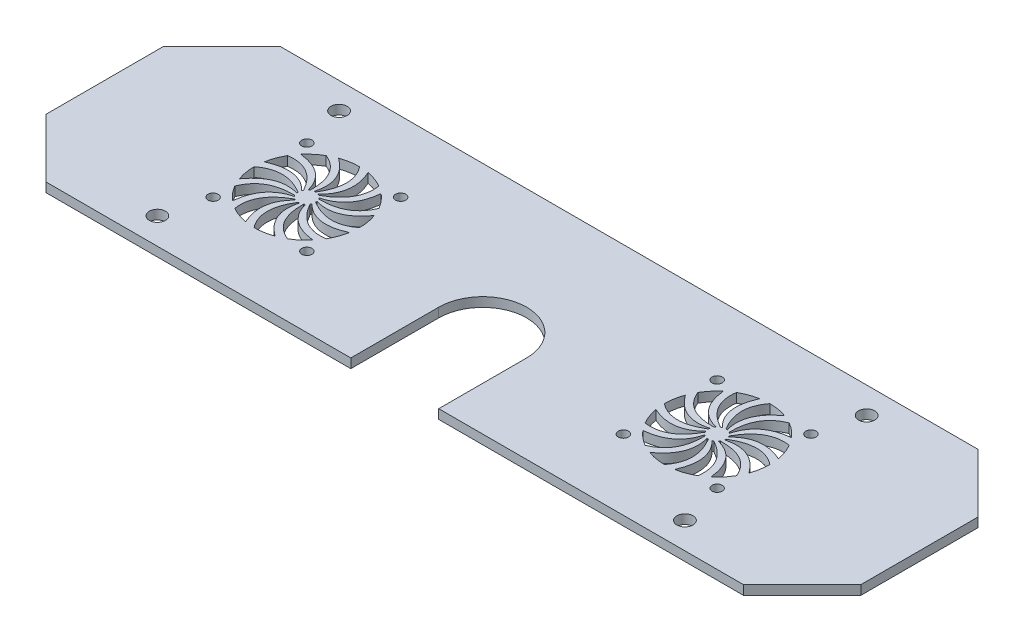
from build123d import *

# Parameters (mm, degrees)
SKETCH1_W             = 278
SKETCH1_H             = 80
BOSS_EXTRUDE1_DEPTH   = 3.175
CHAMFER1_SIZE         = 20
SKETCH2_R             = 1.75
CUT_EXTRUDE1_DEPTH    = 10
SKETCH3_R             = 2.75
CUT_EXTRUDE2_DEPTH    = 10
CUT_EXTRUDE3_DEPTH    = 10
CUT_EXTRUDE8_DEPTH    = 10
CIRPATTERN1_COUNT     = 12
MIRROR1_COPY_1_DEPTH  = 10
MIRROR1_COPY_2_DEPTH  = 10
MIRROR1_COPY_3_DEPTH  = 10
MIRROR1_COPY_4_DEPTH  = 10
MIRROR1_COPY_5_DEPTH  = 10
MIRROR1_COPY_6_DEPTH  = 10
MIRROR1_COPY_7_DEPTH  = 10
MIRROR1_COPY_8_DEPTH  = 10
MIRROR1_COPY_9_DEPTH  = 10
MIRROR1_COPY_10_DEPTH = 10
MIRROR1_COPY_11_DEPTH = 10


with BuildPart() as part:
    # Sketch1 → Boss-Extrude1 (new body)
    with BuildSketch(Plane(origin=(0, 0, 0), x_dir=(1, 0, 0), z_dir=(0, 1, 0))):
        Rectangle(SKETCH1_W, SKETCH1_H)
    extrude(amount=BOSS_EXTRUDE1_DEPTH)

    # Chamfer1
    chamfer1_edges = [part.edges().sort_by_distance(p)[0] for p in [
        (139, 1.5875, 40),
        (139, 1.5875, -40),
        (-139, 1.5875, -40),
        (-139, 1.5875, 40),
    ]]
    chamfer(chamfer1_edges, length=CHAMFER1_SIZE)

    # Sketch2 → Cut-Extrude1 (cut)
    with BuildSketch(Plane(origin=(0, 3.175, 0), x_dir=(1, 0, 0), z_dir=(0, 1, 0))):
        with Locations((-86, 16)):
            Circle(SKETCH2_R)
        with Locations((-54, 16)):
            Circle(SKETCH2_R)
        with Locations((-86, -16)):
            Circle(SKETCH2_R)
        with Locations((-54, -16)):
            Circle(SKETCH2_R)
        with Locations((54, -16)):
            Circle(SKETCH2_R)
        with Locations((86, -16)):
            Circle(SKETCH2_R)
        with Locations((54, 16)):
            Circle(SKETCH2_R)
        with Locations((86, 16)):
            Circle(SKETCH2_R)
    extrude(amount=-CUT_EXTRUDE1_DEPTH, mode=Mode.SUBTRACT)

    # Sketch3 → Cut-Extrude2 (cut)
    with BuildSketch(Plane(origin=(0, 3.175, 0), x_dir=(1, 0, 0), z_dir=(0, 1, 0))):
        with Locations((-90, 31)):
            Circle(SKETCH3_R)
        with Locations((-90, -31)):
            Circle(SKETCH3_R)
        with Locations((90, -31)):
            Circle(SKETCH3_R)
        with Locations((90, 31)):
            Circle(SKETCH3_R)
    extrude(amount=-CUT_EXTRUDE2_DEPTH, mode=Mode.SUBTRACT)

    # Sketch4 → Cut-Extrude3 (cut)
    with BuildSketch(Plane(origin=(0, 3.175, 0), x_dir=(1, 0, 0), z_dir=(0, 1, 0))):
        with BuildLine():
            Line((15, -40), (-15, -40))
            Line((-15, -40), (-15, -10))
            ThreePointArc((-15, -10), (0, 5), (15, -10))
            Line((15, -10), (15, -40))
        make_face()
    extrude(amount=-CUT_EXTRUDE3_DEPTH, mode=Mode.SUBTRACT)

    # Sketch6 → Cut-Extrude8 (cut)
    with BuildSketch(Plane(origin=(0, 3.175, 0), x_dir=(1, 0, 0), z_dir=(0, 1, 0))):
        with BuildLine():
            ThreePointArc((-67, 0), (-67.010104912, 0.246023091), (-67.040351574, 0.490388822))
            add(Edge.make_bspline(
                [(-67.040351574, 0.490388822), (-58.831315054, -1.84378005), (-53.060987789, 6.088502716)],
                knots=[0, 0, 0, 1, 1, 1], degree=2))
            ThreePointArc((-53.060987789, 6.088502716), (-52.26723062, 3.090127846), (-52, 0))
            add(Edge.make_bspline(
                [(-67, 0), (-58.536045734, -5.138256955), (-52, 0)],
                knots=[0, 0, 0, 1, 1, 1], degree=2))
        make_face()
    cut_extrude8 = extrude(amount=-CUT_EXTRUDE8_DEPTH, mode=Mode.SUBTRACT)

    # CirPattern1: Cut-Extrude8 ×12 about axis
    cirpattern1_axis = Axis((-70, 3.175, 0), (0, 1, 0))
    for i in range(1, CIRPATTERN1_COUNT):
        add(cut_extrude8.rotate(cirpattern1_axis, i * 360 / CIRPATTERN1_COUNT), mode=Mode.SUBTRACT)

    # Mirror1: Cut-Extrude8 across plane
    add(cut_extrude8.mirror(Plane(origin=(0, 0, 0), x_dir=(0, 0, 1), z_dir=(1, 0, 0))), mode=Mode.SUBTRACT)

    # Mirror1 copy 1 sketch → Mirror1 copy 1 (cut)
    with BuildSketch(Plane(origin=(9.378221735, 3.175, -35), x_dir=(-0.8660254037844387, 0, -0.49999999999999994), z_dir=(0, 1, 0))):
        with BuildLine():
            ThreePointArc((-67, 0), (-67.010104912, -0.246023091), (-67.040351574, -0.490388822))
            add(Edge.make_bspline(
                [(-67.040351574, -0.490388822), (-58.831315054, 1.84378005), (-53.060987789, -6.088502716)],
                knots=[0, 0, 0, 1, 1, 1], degree=2))
            ThreePointArc((-53.060987789, -6.088502716), (-52.26723062, -3.090127846), (-52, 0))
            add(Edge.make_bspline(
                [(-67, 0), (-58.536045734, 5.138256955), (-52, 0)],
                knots=[0, 0, 0, 1, 1, 1], degree=2))
        make_face()
    extrude(amount=-MIRROR1_COPY_1_DEPTH, mode=Mode.SUBTRACT)

    # Mirror1 copy 2 sketch → Mirror1 copy 2 (cut)
    with BuildSketch(Plane(origin=(35, 3.175, -60.621778265), x_dir=(-0.5000000000000001, 0, -0.8660254037844386), z_dir=(0, 1, 0))):
        with BuildLine():
            ThreePointArc((-67, 0), (-67.010104912, -0.246023091), (-67.040351574, -0.490388822))
            add(Edge.make_bspline(
                [(-67.040351574, -0.490388822), (-58.831315054, 1.84378005), (-53.060987789, -6.088502716)],
                knots=[0, 0, 0, 1, 1, 1], degree=2))
            ThreePointArc((-53.060987789, -6.088502716), (-52.26723062, -3.090127846), (-52, 0))
            add(Edge.make_bspline(
                [(-67, 0), (-58.536045734, 5.138256955), (-52, 0)],
                knots=[0, 0, 0, 1, 1, 1], degree=2))
        make_face()
    extrude(amount=-MIRROR1_COPY_2_DEPTH, mode=Mode.SUBTRACT)

    # Mirror1 copy 3 sketch → Mirror1 copy 3 (cut)
    with BuildSketch(Plane(origin=(70, 3.175, -70), x_dir=(0, 0, -1), z_dir=(0, 1, 0))):
        with BuildLine():
            ThreePointArc((-67, 0), (-67.010104912, -0.246023091), (-67.040351574, -0.490388822))
            add(Edge.make_bspline(
                [(-67.040351574, -0.490388822), (-58.831315054, 1.84378005), (-53.060987789, -6.088502716)],
                knots=[0, 0, 0, 1, 1, 1], degree=2))
            ThreePointArc((-53.060987789, -6.088502716), (-52.26723062, -3.090127846), (-52, 0))
            add(Edge.make_bspline(
                [(-67, 0), (-58.536045734, 5.138256955), (-52, 0)],
                knots=[0, 0, 0, 1, 1, 1], degree=2))
        make_face()
    extrude(amount=-MIRROR1_COPY_3_DEPTH, mode=Mode.SUBTRACT)

    # Mirror1 copy 4 sketch → Mirror1 copy 4 (cut)
    with BuildSketch(Plane(origin=(105, 3.175, -60.621778265), x_dir=(0.4999999999999998, 0, -0.8660254037844387), z_dir=(0, 1, 0))):
        with BuildLine():
            ThreePointArc((-67, 0), (-67.010104912, -0.246023091), (-67.040351574, -0.490388822))
            add(Edge.make_bspline(
                [(-67.040351574, -0.490388822), (-58.831315054, 1.84378005), (-53.060987789, -6.088502716)],
                knots=[0, 0, 0, 1, 1, 1], degree=2))
            ThreePointArc((-53.060987789, -6.088502716), (-52.26723062, -3.090127846), (-52, 0))
            add(Edge.make_bspline(
                [(-67, 0), (-58.536045734, 5.138256955), (-52, 0)],
                knots=[0, 0, 0, 1, 1, 1], degree=2))
        make_face()
    extrude(amount=-MIRROR1_COPY_4_DEPTH, mode=Mode.SUBTRACT)

    # Mirror1 copy 5 sketch → Mirror1 copy 5 (cut)
    with BuildSketch(Plane(origin=(130.621778265, 3.175, -35), x_dir=(0.8660254037844387, 0, -0.49999999999999994), z_dir=(0, 1, 0))):
        with BuildLine():
            ThreePointArc((-67, 0), (-67.010104912, -0.246023091), (-67.040351574, -0.490388822))
            add(Edge.make_bspline(
                [(-67.040351574, -0.490388822), (-58.831315054, 1.84378005), (-53.060987789, -6.088502716)],
                knots=[0, 0, 0, 1, 1, 1], degree=2))
            ThreePointArc((-53.060987789, -6.088502716), (-52.26723062, -3.090127846), (-52, 0))
            add(Edge.make_bspline(
                [(-67, 0), (-58.536045734, 5.138256955), (-52, 0)],
                knots=[0, 0, 0, 1, 1, 1], degree=2))
        make_face()
    extrude(amount=-MIRROR1_COPY_5_DEPTH, mode=Mode.SUBTRACT)

    # Mirror1 copy 6 sketch → Mirror1 copy 6 (cut)
    with BuildSketch(Plane(origin=(140, 3.175, 0), x_dir=(1, 0, 0), z_dir=(0, 1, 0))):
        with BuildLine():
            ThreePointArc((-67, 0), (-67.010104912, -0.246023091), (-67.040351574, -0.490388822))
            add(Edge.make_bspline(
                [(-67.040351574, -0.490388822), (-58.831315054, 1.84378005), (-53.060987789, -6.088502716)],
                knots=[0, 0, 0, 1, 1, 1], degree=2))
            ThreePointArc((-53.060987789, -6.088502716), (-52.26723062, -3.090127846), (-52, 0))
            add(Edge.make_bspline(
                [(-67, 0), (-58.536045734, 5.138256955), (-52, 0)],
                knots=[0, 0, 0, 1, 1, 1], degree=2))
        make_face()
    extrude(amount=-MIRROR1_COPY_6_DEPTH, mode=Mode.SUBTRACT)

    # Mirror1 copy 7 sketch → Mirror1 copy 7 (cut)
    with BuildSketch(Plane(origin=(130.621778265, 3.175, 35), x_dir=(0.8660254037844386, 0, 0.5000000000000001), z_dir=(0, 1, 0))):
        with BuildLine():
            ThreePointArc((-67, 0), (-67.010104912, -0.246023091), (-67.040351574, -0.490388822))
            add(Edge.make_bspline(
                [(-67.040351574, -0.490388822), (-58.831315054, 1.84378005), (-53.060987789, -6.088502716)],
                knots=[0, 0, 0, 1, 1, 1], degree=2))
            ThreePointArc((-53.060987789, -6.088502716), (-52.26723062, -3.090127846), (-52, 0))
            add(Edge.make_bspline(
                [(-67, 0), (-58.536045734, 5.138256955), (-52, 0)],
                knots=[0, 0, 0, 1, 1, 1], degree=2))
        make_face()
    extrude(amount=-MIRROR1_COPY_7_DEPTH, mode=Mode.SUBTRACT)

    # Mirror1 copy 8 sketch → Mirror1 copy 8 (cut)
    with BuildSketch(Plane(origin=(105, 3.175, 60.621778265), x_dir=(0.5000000000000004, 0, 0.8660254037844384), z_dir=(0, 1, 0))):
        with BuildLine():
            ThreePointArc((-67, 0), (-67.010104912, -0.246023091), (-67.040351574, -0.490388822))
            add(Edge.make_bspline(
                [(-67.040351574, -0.490388822), (-58.831315054, 1.84378005), (-53.060987789, -6.088502716)],
                knots=[0, 0, 0, 1, 1, 1], degree=2))
            ThreePointArc((-53.060987789, -6.088502716), (-52.26723062, -3.090127846), (-52, 0))
            add(Edge.make_bspline(
                [(-67, 0), (-58.536045734, 5.138256955), (-52, 0)],
                knots=[0, 0, 0, 1, 1, 1], degree=2))
        make_face()
    extrude(amount=-MIRROR1_COPY_8_DEPTH, mode=Mode.SUBTRACT)

    # Mirror1 copy 9 sketch → Mirror1 copy 9 (cut)
    with BuildSketch(Plane(origin=(70, 3.175, 70), x_dir=(0, 0, 1), z_dir=(0, 1, 0))):
        with BuildLine():
            ThreePointArc((-67, 0), (-67.010104912, -0.246023091), (-67.040351574, -0.490388822))
            add(Edge.make_bspline(
                [(-67.040351574, -0.490388822), (-58.831315054, 1.84378005), (-53.060987789, -6.088502716)],
                knots=[0, 0, 0, 1, 1, 1], degree=2))
            ThreePointArc((-53.060987789, -6.088502716), (-52.26723062, -3.090127846), (-52, 0))
            add(Edge.make_bspline(
                [(-67, 0), (-58.536045734, 5.138256955), (-52, 0)],
                knots=[0, 0, 0, 1, 1, 1], degree=2))
        make_face()
    extrude(amount=-MIRROR1_COPY_9_DEPTH, mode=Mode.SUBTRACT)

    # Mirror1 copy 10 sketch → Mirror1 copy 10 (cut)
    with BuildSketch(Plane(origin=(35, 3.175, 60.621778265), x_dir=(-0.5000000000000001, 0, 0.8660254037844386), z_dir=(0, 1, 0))):
        with BuildLine():
            ThreePointArc((-67, 0), (-67.010104912, -0.246023091), (-67.040351574, -0.490388822))
            add(Edge.make_bspline(
                [(-67.040351574, -0.490388822), (-58.831315054, 1.84378005), (-53.060987789, -6.088502716)],
                knots=[0, 0, 0, 1, 1, 1], degree=2))
            ThreePointArc((-53.060987789, -6.088502716), (-52.26723062, -3.090127846), (-52, 0))
            add(Edge.make_bspline(
                [(-67, 0), (-58.536045734, 5.138256955), (-52, 0)],
                knots=[0, 0, 0, 1, 1, 1], degree=2))
        make_face()
    extrude(amount=-MIRROR1_COPY_10_DEPTH, mode=Mode.SUBTRACT)

    # Mirror1 copy 11 sketch → Mirror1 copy 11 (cut)
    with BuildSketch(Plane(origin=(9.378221735, 3.175, 35), x_dir=(-0.8660254037844384, 0, 0.5000000000000004), z_dir=(0, 1, 0))):
        with BuildLine():
            ThreePointArc((-67, 0), (-67.010104912, -0.246023091), (-67.040351574, -0.490388822))
            add(Edge.make_bspline(
                [(-67.040351574, -0.490388822), (-58.831315054, 1.84378005), (-53.060987789, -6.088502716)],
                knots=[0, 0, 0, 1, 1, 1], degree=2))
            ThreePointArc((-53.060987789, -6.088502716), (-52.26723062, -3.090127846), (-52, 0))
            add(Edge.make_bspline(
                [(-67, 0), (-58.536045734, 5.138256955), (-52, 0)],
                knots=[0, 0, 0, 1, 1, 1], degree=2))
        make_face()
    extrude(amount=-MIRROR1_COPY_11_DEPTH, mode=Mode.SUBTRACT)


solid = part.part
